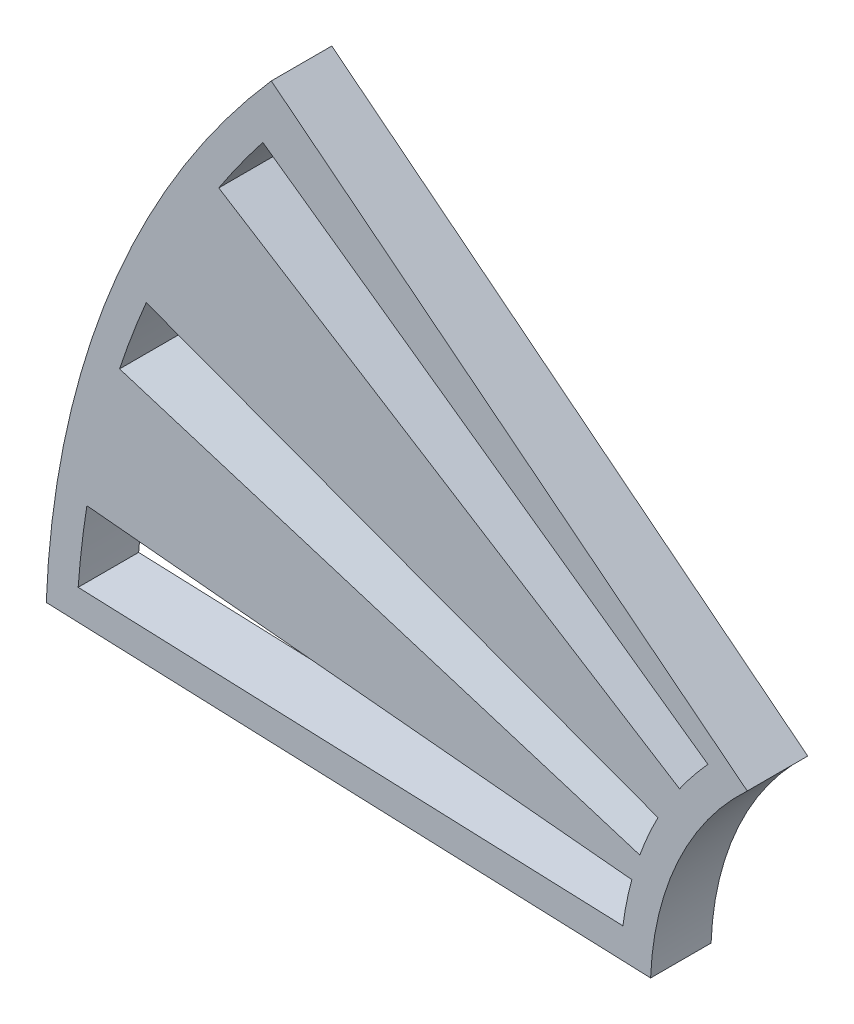
from build123d import *

# Parameters (mm, degrees)
BOSS_EXTRUDE2_DEPTH = 4
CUT_EXTRUDE1_DEPTH  = 72.966153215


with BuildPart() as part:
    # Sketch1 → Boss-Extrude2 (new body)
    with BuildSketch(Plane.XY):
        with BuildLine():
            Line((-19.985447982, 0.762803358), (-59.956343946, 2.288410074))
            ThreePointArc((-59.956343946, 2.288410074), (-55.730717245, 22.228071336), (-45.073672701, 39.602576043))
            Line((-45.073672701, 39.602576043), (-13.592462366, 14.67122922))
            ThreePointArc((-13.592462366, 14.67122922), (-18.172234131, 8.352838241), (-19.985447982, 0.762803358))
        make_face()
    extrude(amount=BOSS_EXTRUDE2_DEPTH)

    # Sketch1_5 → Cut-Extrude1 (cut, through all)
    with BuildSketch(Plane.XY):
        with BuildLine():
            ThreePointArc((-18.067243214, 12.552877066), (-17.245912522, 13.659374118), (-16.356919422, 14.712280144))
            Line((-16.356919422, 14.712280144), (-16.19149009, 14.894148135))
            Line((-16.19149009, 14.894148135), (-45.633154018, 35.799654388))
            ThreePointArc((-45.633154018, 35.799654388), (-47.133831778, 33.799436415), (-48.546898537, 31.736393028))
            Line((-48.546898537, 31.736393028), (-18.067243214, 12.552877066))
        make_face()
        with BuildLine():
            Line((-57.847050894, 4.209358967), (-21.816681027, 2.834154011))
            ThreePointArc((-21.816681027, 2.834154011), (-21.572673921, 4.315059664), (-21.2282638, 5.775882272))
            Line((-21.2282638, 5.775882272), (-57.269563461, 9.175897829))
            ThreePointArc((-57.269563461, 9.175897829), (-57.611850796, 6.698854216), (-57.847050894, 4.209358967))
        make_face()
        with BuildLine():
            Line((-55.106686022, 18.090139737), (-20.700540486, 7.449001516))
            ThreePointArc((-20.700540486, 7.449001516), (-20.144482043, 8.843067523), (-19.494667642, 10.19597634))
            Line((-19.494667642, 10.19597634), (-53.343874365, 22.769081398))
            ThreePointArc((-53.343874365, 22.769081398), (-54.275723264, 20.448615214), (-55.106686022, 18.090139737))
        make_face()
    extrude(amount=CUT_EXTRUDE1_DEPTH, mode=Mode.SUBTRACT)


solid = part.part
